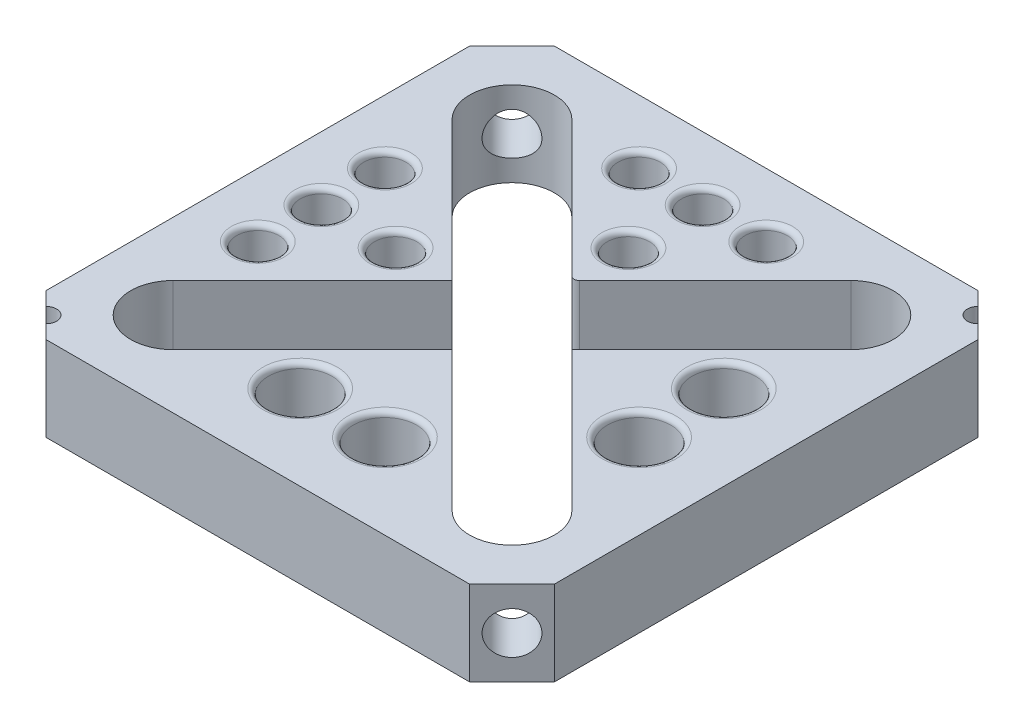
from build123d import *

# Parameters (mm, degrees)
SKETCH1_W           = 76.2
SKETCH1_H           = 76.2
BOSS_EXTRUDE1_DEPTH = 12.7
CUT_EXTRUDE1_DEPTH  = 13.7
SKETCH4_R           = 3.175
SKETCH4_R_2         = 4.7625
CUT_EXTRUDE3_DEPTH  = 13.7
FILLET4_R           = 0.79375
FILLET5_R           = 0.79375
FILLET6_R           = 0.79375
FILLET7_R           = 0.79375
CUT_EXTRUDE5_DEPTH  = 13.7
SKETCH6_R           = 1.5875
CUT_EXTRUDE6_DEPTH  = 13.7
SKETCH7_R           = 3.175
CUT_EXTRUDE7_DEPTH  = 10.414
SKETCH8_R           = 3.175
CUT_EXTRUDE8_DEPTH  = 10.414


with BuildPart() as part:
    # Sketch1 → Boss-Extrude1 (new body)
    with BuildSketch(Plane(origin=(0, 0, 0), x_dir=(1, 0, 0), z_dir=(0, 1, 0))):
        with Locations((38.1, 38.1)):
            Rectangle(SKETCH1_W, SKETCH1_H)
    extrude(amount=BOSS_EXTRUDE1_DEPTH)

    # Sketch3 → Cut-Extrude1 (cut, through all)
    with BuildSketch(Plane(origin=(0, 0, 0), x_dir=(-1, 0, 0), z_dir=(0, -1, 0))):
        with BuildLine():
            Line((-67.988603243, 59.007810639), (-47.080200842, 38.099408239))
            Line((-47.080200842, 38.099408239), (-67.973446843, 17.206162238))
            ThreePointArc((-67.973446843, 17.206162238), (-67.973446843, 8.225906117), (-58.993190722, 8.225906117))
            Line((-58.993190722, 8.225906117), (-38.099944721, 29.119152118))
            Line((-38.099944721, 29.119152118), (-17.188603243, 8.207810639))
            ThreePointArc((-17.188603243, 8.207810639), (-8.208347122, 8.207810639), (-8.208347122, 17.18806676))
            Line((-8.208347122, 17.18806676), (-29.118219061, 38.0979387))
            Line((-29.118219061, 38.0979387), (-8.208347122, 59.007810639))
            ThreePointArc((-8.208347122, 59.007810639), (-8.208347122, 67.98806676), (-17.188603243, 67.98806676))
            Line((-17.188603243, 67.98806676), (-38.098475182, 47.078194821))
            Line((-38.098475182, 47.078194821), (-59.008347122, 67.98806676))
            ThreePointArc((-59.008347122, 67.98806676), (-67.988603243, 67.98806676), (-67.988603243, 59.007810639))
        make_face()
    extrude(amount=-CUT_EXTRUDE1_DEPTH, mode=Mode.SUBTRACT)

    # Sketch4 → Cut-Extrude3 (cut, through all)
    with BuildSketch(Plane(origin=(0, 12.7, 0), x_dir=(1, 0, 0), z_dir=(0, 1, 0))):
        with Locations((9.525, 28.575)):
            Circle(SKETCH4_R)
        with Locations((9.525, 38.1)):
            Circle(SKETCH4_R)
        with Locations((9.525, 47.625)):
            Circle(SKETCH4_R)
        with Locations((20.6502, 38.1)):
            Circle(SKETCH4_R)
        with Locations((28.575, 66.675)):
            Circle(SKETCH4_R)
        with Locations((38.1, 66.675)):
            Circle(SKETCH4_R)
        with Locations((47.625, 66.675)):
            Circle(SKETCH4_R)
        with Locations((38.1, 55.5498)):
            Circle(SKETCH4_R)
        with Locations((31.75, 12.7)):
            Circle(SKETCH4_R_2)
        with Locations((63.5, 31.75)):
            Circle(SKETCH4_R_2)
        with Locations((63.5, 44.45)):
            Circle(SKETCH4_R_2)
        with Locations((44.45, 12.7)):
            Circle(SKETCH4_R_2)
    extrude(amount=-CUT_EXTRUDE3_DEPTH, mode=Mode.SUBTRACT)

    # Fillet4
    fillet4_edges = [part.edges().sort_by_distance(p)[0] for p in [
        (6.35, 0, -28.575),
        (6.35, 12.7, -28.575),
        (17.4752, 0, -38.1),
        (17.4752, 12.7, -38.1),
        (6.35, 0, -47.625),
        (6.35, 12.7, -47.625),
        (6.35, 0, -38.1),
        (6.35, 12.7, -38.1),
    ]]
    fillet(fillet4_edges, radius=FILLET4_R)

    # Fillet5
    fillet5_edges = [part.edges().sort_by_distance(p)[0] for p in [
        (38.098475182, 6.35, -47.078194821),
        (44.45, 0, -66.675),
        (44.45, 12.7, -66.675),
        (34.925, 0, -55.5498),
        (34.925, 12.7, -55.5498),
        (34.925, 0, -66.675),
        (34.925, 12.7, -66.675),
        (25.4, 0, -66.675),
        (25.4, 12.7, -66.675),
    ]]
    fillet(fillet5_edges, radius=FILLET5_R)

    # Fillet6
    fillet6_edges = [part.edges().sort_by_distance(p)[0] for p in [
        (58.7375, 0, -31.75),
        (58.7375, 12.7, -31.75),
        (58.7375, 0, -44.45),
        (58.7375, 12.7, -44.45),
    ]]
    fillet(fillet6_edges, radius=FILLET6_R)

    # Fillet7
    fillet7_edges = [part.edges().sort_by_distance(p)[0] for p in [
        (26.9875, 0, -12.7),
        (26.9875, 12.7, -12.7),
        (39.6875, 0, -12.7),
        (39.6875, 12.7, -12.7),
    ]]
    fillet(fillet7_edges, radius=FILLET7_R)

    # Sketch5 → Cut-Extrude5 (cut, through all)
    with BuildSketch(Plane(origin=(0, 12.7, 0), x_dir=(1, 0, 0), z_dir=(0, 1, 0))):
        Polygon((0, 6.35), (6.35, 0), (0, 0), align=None)
        Polygon((0, 76.2), (0, 69.85), (6.35, 76.2), align=None)
        Polygon((69.85, 76.2), (76.2, 69.85), (76.2, 76.2), align=None)
        Polygon((69.85, 0), (76.2, 6.35), (76.2, 0), align=None)
    extrude(amount=-CUT_EXTRUDE5_DEPTH, mode=Mode.SUBTRACT)

    # Sketch6 → Cut-Extrude6 (cut, through all)
    with BuildSketch(Plane(origin=(0, 12.7, 0), x_dir=(1, 0, 0), z_dir=(0, 1, 0))):
        with Locations((3.175, 3.175)):
            Circle(SKETCH6_R)
        with Locations((73.025, 73.025)):
            Circle(SKETCH6_R)
    extrude(amount=-CUT_EXTRUDE6_DEPTH, mode=Mode.SUBTRACT)

    # Sketch7 → Cut-Extrude7 (cut)
    with BuildSketch(Plane(origin=(34.925, 0, 34.925), x_dir=(0.707106781, 0, -0.707106781), z_dir=(0.707106781, 0, 0.707106781))):
        with Locations((53.881536726, 6.35)):
            Circle(SKETCH7_R)
    extrude(amount=-CUT_EXTRUDE7_DEPTH, mode=Mode.SUBTRACT)

    # Sketch8 → Cut-Extrude8 (cut)
    with BuildSketch(Plane(origin=(-34.925, 0, -34.925), x_dir=(-0.707106781, 0, 0.707106781), z_dir=(-0.707106781, 0, -0.707106781))):
        with Locations((-53.881536726, 6.35)):
            Circle(SKETCH8_R)
    extrude(amount=-CUT_EXTRUDE8_DEPTH, mode=Mode.SUBTRACT)


solid = part.part
